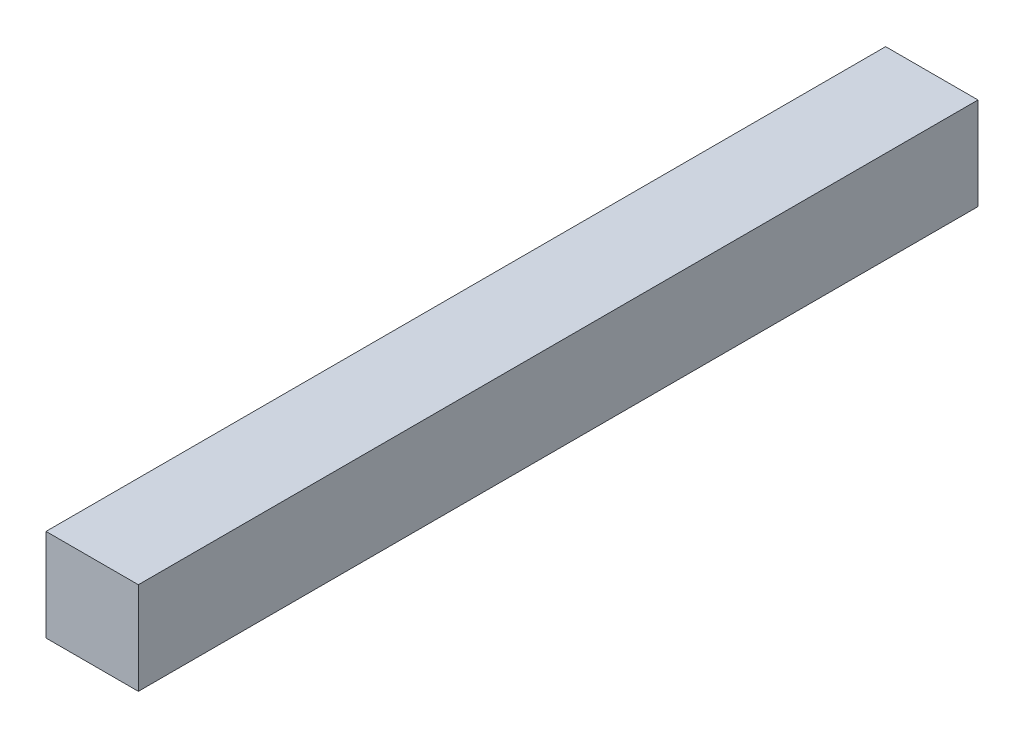
from build123d import *

# Parameters (mm, degrees)
ESQUISSE1_W      = 22
ESQUISSE1_H      = 22
EXTRUSION1_DEPTH = 200


with BuildPart() as part:
    # Esquisse1 → Extrusion1 (new body)
    with BuildSketch(Plane.XY):
        with Locations((11, 11)):
            Rectangle(ESQUISSE1_W, ESQUISSE1_H)
    extrude(amount=-EXTRUSION1_DEPTH)


solid = part.part
